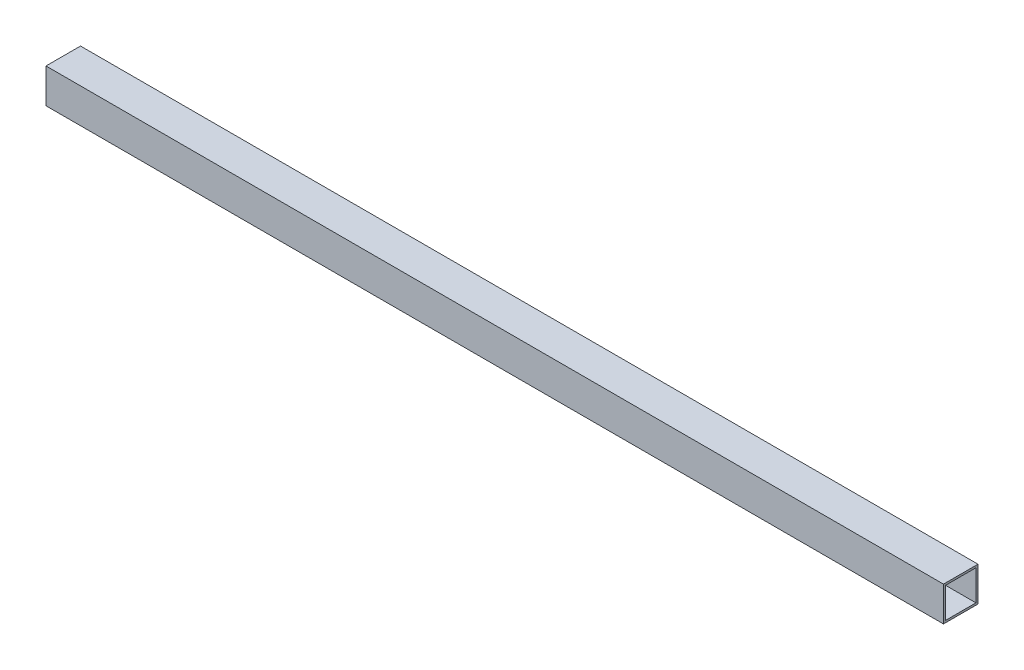
from build123d import *

# Parameters (mm, degrees)
SKETCH1_W           = 20
SKETCH1_H           = 20
SKETCH1_W_2         = 17.6
SKETCH1_H_2         = 17.6
BOSS_EXTRUDE1_DEPTH = 520


with BuildPart() as part:
    # Sketch1 → Boss-Extrude1 (new body)
    with BuildSketch(Plane(origin=(0, 0, 0), x_dir=(0, 0, -1), z_dir=(1, 0, 0))):
        Rectangle(SKETCH1_W, SKETCH1_H)
        Rectangle(SKETCH1_W_2, SKETCH1_H_2, mode=Mode.SUBTRACT)
    extrude(amount=BOSS_EXTRUDE1_DEPTH)


solid = part.part
